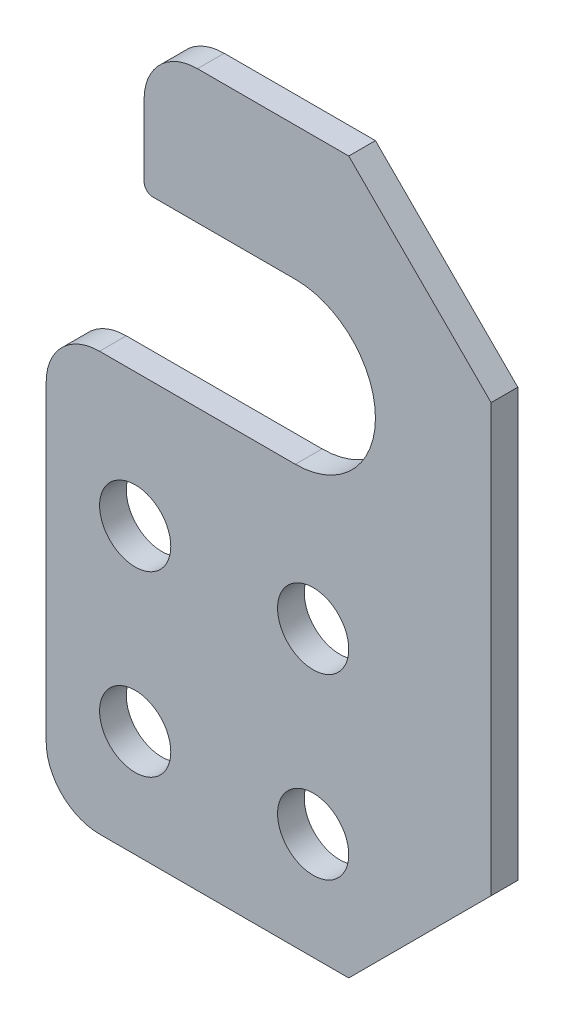
from build123d import *

# Parameters (mm, degrees)
SKETCH1_W           = 30
SKETCH1_H           = 40
SKETCH1_R           = 2
BOSS_EXTRUDE1_DEPTH = 1.5
CHAMFER1_SIZE       = 8
CUT_EXTRUDE1_DEPTH  = 5
FILLET1_R           = 3
FILLET2_R           = 0.5


with BuildPart() as part:
    # Sketch1 → Boss-Extrude1 (new body)
    with BuildSketch(Plane.XY):
        with Locations((15, -20)):
            Rectangle(SKETCH1_W, SKETCH1_H)
        with Locations((20, -34)):
            Circle(SKETCH1_R, mode=Mode.SUBTRACT)
        with Locations((10, -34)):
            Circle(SKETCH1_R, mode=Mode.SUBTRACT)
        with Locations((20, -24)):
            Circle(SKETCH1_R, mode=Mode.SUBTRACT)
        with Locations((10, -24)):
            Circle(SKETCH1_R, mode=Mode.SUBTRACT)
    extrude(amount=BOSS_EXTRUDE1_DEPTH)

    # Chamfer1
    chamfer1_edges = [part.edges().sort_by_distance(p)[0] for p in [
        (30, 0, 0.75),
        (30, -40, 0.75),
    ]]
    chamfer(chamfer1_edges, length=CHAMFER1_SIZE)

    # Sketch2 → Cut-Extrude1 (cut)
    with BuildSketch(Plane.XY.offset(1.5)):
        with BuildLine():
            Line((5, -16.5), (19, -16.5))
            ThreePointArc((19, -16.5), (23.5, -12), (19, -7.5))
            Line((19, -7.5), (10.5, -7.5))
            Line((10.5, -7.5), (10.5, 0))
            Line((10.5, 0), (0, 0))
            Line((0, 0), (0, -16.5))
            Line((0, -16.5), (0, -40))
            Line((0, -40), (5, -40))
            Line((5, -40), (5, -16.5))
        make_face()
    extrude(amount=-CUT_EXTRUDE1_DEPTH, mode=Mode.SUBTRACT)

    # Fillet1
    fillet1_edges = [part.edges().sort_by_distance(p)[0] for p in [
        (10.5, 0, 0.75),
        (5, -40, 0.75),
        (5, -16.5, 0.75),
    ]]
    fillet(fillet1_edges, radius=FILLET1_R)

    # Fillet2
    fillet2_edges = [part.edges().sort_by_distance(p)[0] for p in [
        (10.5, -7.5, 0.75),
    ]]
    fillet(fillet2_edges, radius=FILLET2_R)


solid = part.part
